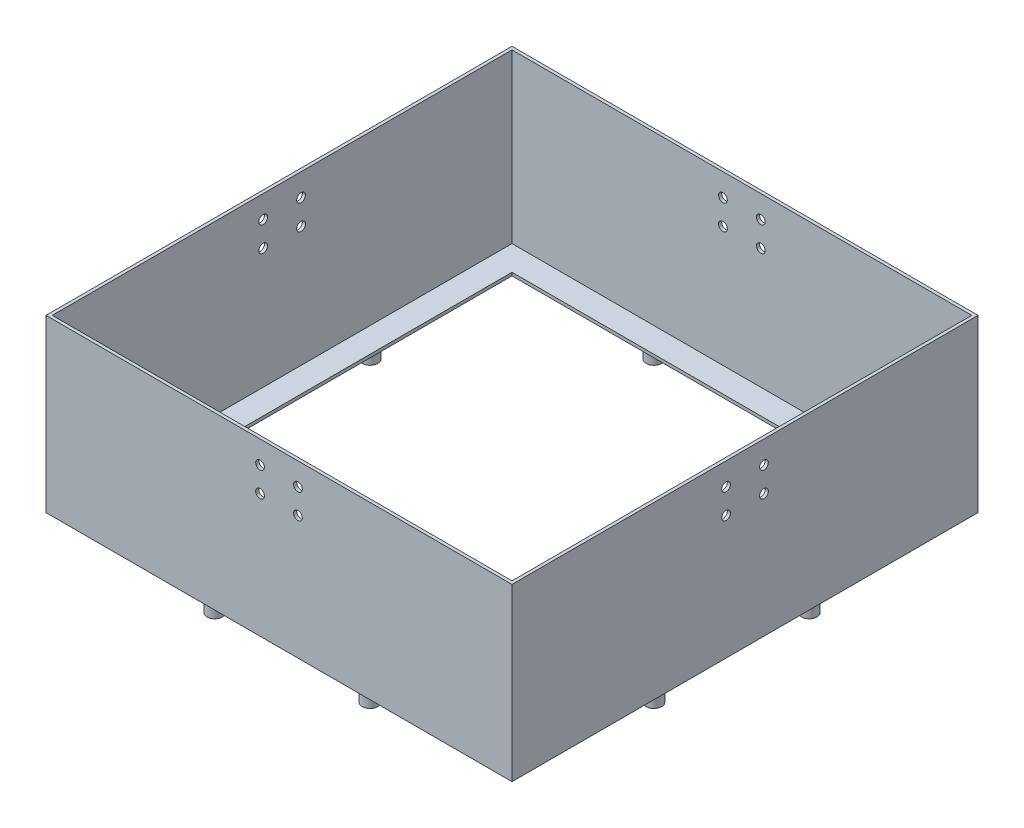
from build123d import *

# Parameters (mm, degrees)
SKETCH1_W           = 150
SKETCH1_H           = 150
BOSS_EXTRUDE1_DEPTH = 55
SKETCH2_W           = 148
SKETCH2_H           = 148
CUT_EXTRUDE1_DEPTH  = 54
SKETCH3_W           = 132
SKETCH3_H           = 132
CUT_EXTRUDE2_DEPTH  = 2
SKETCH6_R           = 2.5
BOSS_EXTRUDE5_DEPTH = 5
SKETCH9_R           = 1.4
CUT_EXTRUDE4_DEPTH  = 10
CIRPATTERN1_COUNT   = 4


with BuildPart() as part:
    # Sketch1 → Boss-Extrude1 (new body)
    with BuildSketch(Plane(origin=(0, 0, 0), x_dir=(1, 0, 0), z_dir=(0, 1, 0))):
        Rectangle(SKETCH1_W, SKETCH1_H)
    extrude(amount=-BOSS_EXTRUDE1_DEPTH)

    # Sketch2 → Cut-Extrude1 (cut)
    with BuildSketch(Plane(origin=(0, 0, 0), x_dir=(1, 0, 0), z_dir=(0, 1, 0))):
        Rectangle(SKETCH2_W, SKETCH2_H)
    extrude(amount=-CUT_EXTRUDE1_DEPTH, mode=Mode.SUBTRACT)

    # Sketch3 → Cut-Extrude2 (cut, through all)
    with BuildSketch(Plane(origin=(0, -54, 0), x_dir=(1, 0, 0), z_dir=(0, 1, 0))):
        Rectangle(SKETCH3_W, SKETCH3_H)
    extrude(amount=-CUT_EXTRUDE2_DEPTH, mode=Mode.SUBTRACT)

    # Sketch6 → Boss-Extrude5 (add)
    with BuildSketch(Plane.XZ.offset(55)):
        with Locations((-70.678187872, -25)):
            Circle(SKETCH6_R)
        with Locations((-70.678187872, 25)):
            Circle(SKETCH6_R)
        with Locations((25, 70.678187872)):
            Circle(SKETCH6_R)
        with Locations((-25, 70.678187872)):
            Circle(SKETCH6_R)
        with Locations((70.678187872, -25)):
            Circle(SKETCH6_R)
        with Locations((70.678187872, 25)):
            Circle(SKETCH6_R)
        with Locations((-25, -70.678187872)):
            Circle(SKETCH6_R)
        with Locations((25, -70.678187872)):
            Circle(SKETCH6_R)
    extrude(amount=BOSS_EXTRUDE5_DEPTH)

    # Sketch9 → Cut-Extrude4 (cut)
    with BuildSketch(Plane.ZY.offset(75)):
        with Locations((-6.1, -7.25)):
            Circle(SKETCH9_R)
        with Locations((6.1, -7.25)):
            Circle(SKETCH9_R)
        with Locations((6.1, -15.25)):
            Circle(SKETCH9_R)
        with Locations((-6.1, -15.25)):
            Circle(SKETCH9_R)
    cut_extrude4 = extrude(amount=-CUT_EXTRUDE4_DEPTH, mode=Mode.SUBTRACT)

    # CirPattern1: Cut-Extrude4 ×4 about axis
    cirpattern1_axis = Axis((0, 0, 0), (0, 1, 0))
    for i in range(1, CIRPATTERN1_COUNT):
        add(cut_extrude4.rotate(cirpattern1_axis, i * 360 / CIRPATTERN1_COUNT), mode=Mode.SUBTRACT)


solid = part.part
